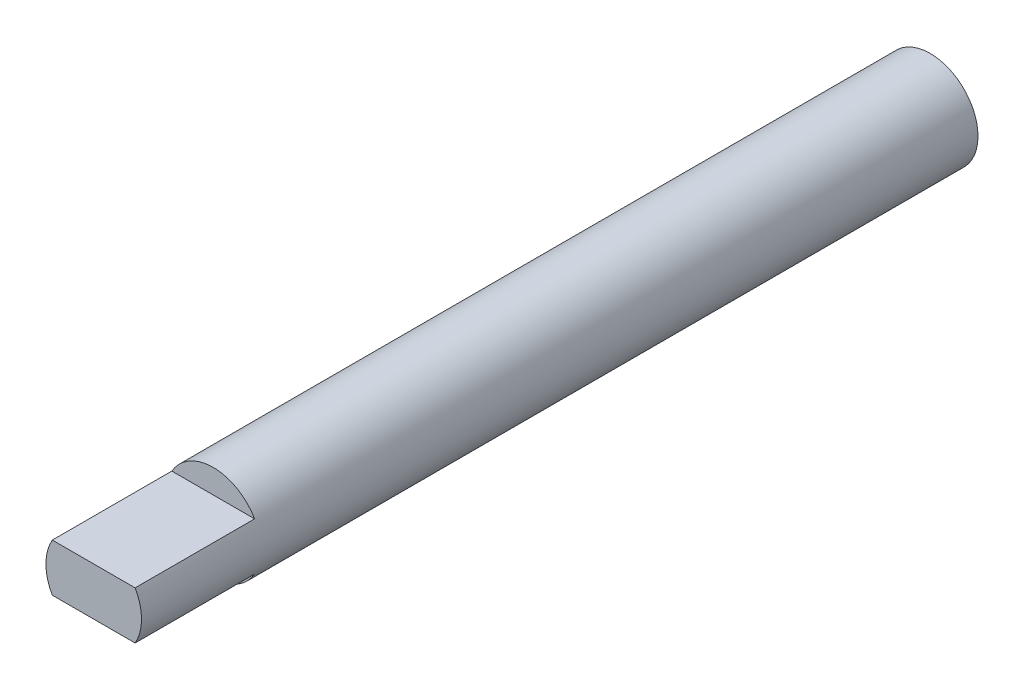
from build123d import *

# Parameters (mm, degrees)
SKETCH1_R           = 4
BOSS_EXTRUDE1_DEPTH = 35
SKETCH2_W           = 8
SKETCH2_H           = 2.52995071
CUT_EXTRUDE1_DEPTH  = 10


with BuildPart() as part:
    # Sketch1 → Boss-Extrude1 (new body, symmetric)
    with BuildSketch(Plane.XY):
        Circle(SKETCH1_R)
    extrude(amount=BOSS_EXTRUDE1_DEPTH, both=True)

    # Sketch2 → Cut-Extrude1 (cut)
    with BuildSketch(Plane.XY.offset(35)):
        Polygon((-4, -2), (4, -2), (4, -4.561964496), (-4, -4.711362164), align=None)
        with Locations((0, 3.264975355)):
            Rectangle(SKETCH2_W, SKETCH2_H)
    extrude(amount=-CUT_EXTRUDE1_DEPTH, mode=Mode.SUBTRACT)


solid = part.part
